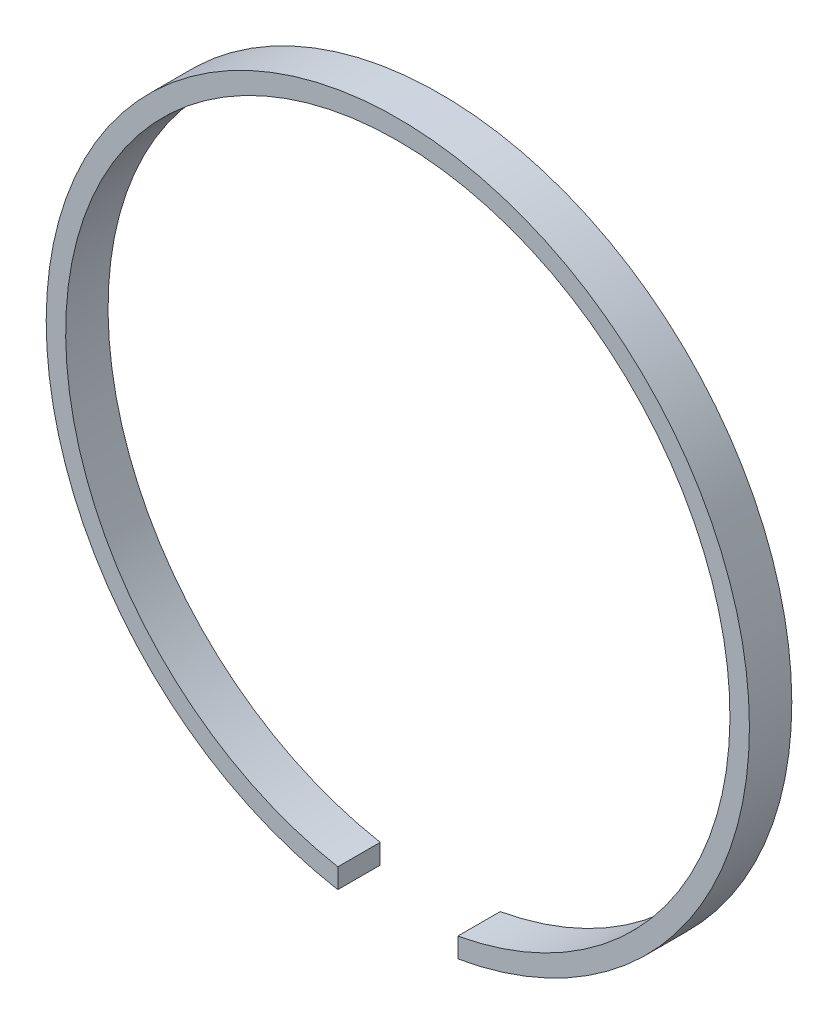
from build123d import *

# Parameters (mm, degrees)
SKETCH1_R           = 30.7
SKETCH1_R_2         = 29
BOSS_EXTRUDE1_DEPTH = 3.7
SKETCH2_W           = 10.47434743
SKETCH2_H           = 20.699601854
CUT_EXTRUDE1_DEPTH  = 58


with BuildPart() as part:
    # Sketch1 → Boss-Extrude1 (new body)
    with BuildSketch(Plane.XY):
        Circle(SKETCH1_R)
        Circle(SKETCH1_R_2, mode=Mode.SUBTRACT)
    extrude(amount=BOSS_EXTRUDE1_DEPTH)

    # Sketch2 → Cut-Extrude1 (cut)
    with BuildSketch(Plane(origin=(0, 0, 0), x_dir=(1, 0, 0), z_dir=(0, 1, 0))):
        Rectangle(SKETCH2_W, SKETCH2_H)
    extrude(amount=-CUT_EXTRUDE1_DEPTH, mode=Mode.SUBTRACT)


solid = part.part
